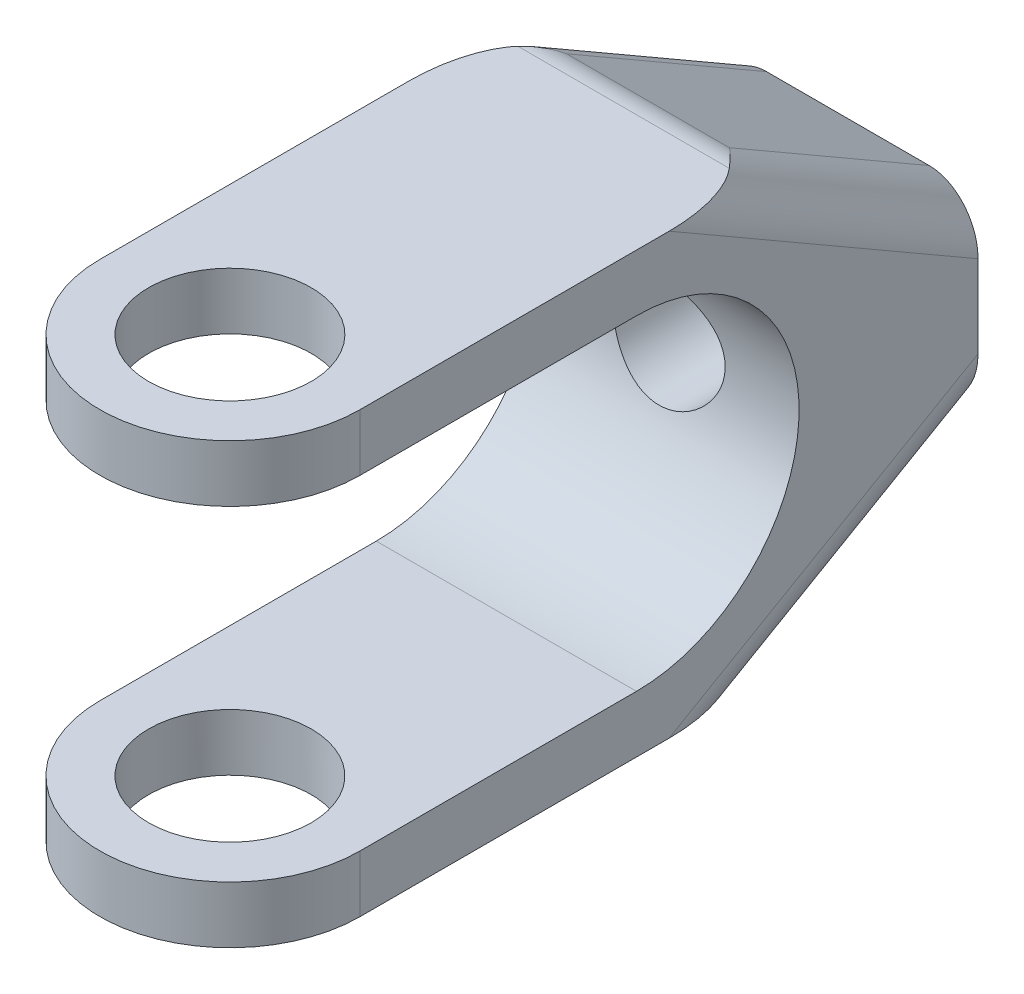
from build123d import *

# Parameters (mm, degrees)
SKETCH1_W                = 22
SKETCH1_H                = 27
EXTRUDE1_DEPTH           = 60
EXTRUDE2_DEPTH           = 12
EXTRUDE2_DEPTH_BACK      = 12
SKETCH3_R                = 5
EXTRUDE3_DEPTH           = 14.5
EXTRUDE3_DEPTH_BACK      = 14.5
F_5_16_24_TAPPED_HOLE2_D = 6.9088
CUT_EXTRUDE1_DEPTH       = 9.0000001
CUT_EXTRUDE1_DEPTH_BACK  = 9.0000001
FILLET2_R                = 3


with BuildPart() as part:
    # Sketch1 → Extrude1 (new body)
    with BuildSketch(Plane.XY):
        Rectangle(SKETCH1_W, SKETCH1_H)
    extrude(amount=EXTRUDE1_DEPTH)

    # Sketch2 → Extrude2 (cut, two sides)
    with BuildSketch(Plane(origin=(0, 0, 0), x_dir=(0, 0, -1), z_dir=(1, 0, 0))) as extrude2_sk:
        with BuildLine():
            Line((-66.910918786, 10), (-21, 10))
            ThreePointArc((-21, 10), (-11, 0), (-21, -10))
            Line((-21, -10), (-66.910918786, -10))
            Line((-66.910918786, -10), (-66.910918786, 10))
        make_face()
    extrude(amount=EXTRUDE2_DEPTH, mode=Mode.SUBTRACT)
    extrude(extrude2_sk.sketch, amount=-EXTRUDE2_DEPTH_BACK, mode=Mode.SUBTRACT)

    # Sketch3 → Extrude3 (cut, two sides)
    with BuildSketch(Plane(origin=(0, 0, 0), x_dir=(1, 0, 0), z_dir=(0, 1, 0))) as extrude3_sk:
        with Locations((0, -38)):
            Circle(SKETCH3_R)
        with BuildLine():
            Line((-8, -38), (-8, 11.717299326))
            Line((-8, 11.717299326), (-29.903870298, 11.717299326))
            Line((-29.903870298, 11.717299326), (-29.903870298, -74.658770221))
            Line((-29.903870298, -74.658770221), (37.768949852, -74.658770221))
            Line((37.768949852, -74.658770221), (37.768949852, 11.717299326))
            Line((37.768949852, 11.717299326), (8, 11.717299326))
            Line((8, 11.717299326), (8, -38))
            ThreePointArc((8, -38), (0, -46), (-8, -38))
        make_face()
    extrude(amount=EXTRUDE3_DEPTH, mode=Mode.SUBTRACT)
    extrude(extrude3_sk.sketch, amount=-EXTRUDE3_DEPTH_BACK, mode=Mode.SUBTRACT)

    # 5_16-24 Tapped Hole2 (through all)
    with Locations(Plane(origin=(0, 0, 0), x_dir=(-1, 0, 0), z_dir=(0, 0, -1))):
        with Locations((0, 0)):
            Hole(F_5_16_24_TAPPED_HOLE2_D / 2)

    # Sketch8 → Cut-Extrude1 (cut, two sides)
    with BuildSketch(Plane(origin=(0, 0, 0), x_dir=(0, 0, -1), z_dir=(1, 0, 0))) as cut_extrude1_sk:
        Polygon((0, -6), (0, 6), (-17.643434352, 16.186441572), (9.090258644, 16.186441572), (9.090258644, -16.186441572), (-17.643434352, -16.186441572), align=None)
    extrude(amount=CUT_EXTRUDE1_DEPTH, mode=Mode.SUBTRACT)
    extrude(cut_extrude1_sk.sketch, amount=-CUT_EXTRUDE1_DEPTH_BACK, mode=Mode.SUBTRACT)

    # Fillet2
    fillet2_edges = [part.edges().sort_by_distance(p)[0] for p in [
        (-8, 9.75, 6.495190528),
        (8, 9.75, 6.495190528),
        (8, -9.75, 6.495190528),
        (0, 13.5, 12.990381057),
        (-8, -9.75, 6.495190528),
        (0, -13.5, 12.990381057),
    ]]
    fillet(fillet2_edges, radius=FILLET2_R)


solid = part.part
